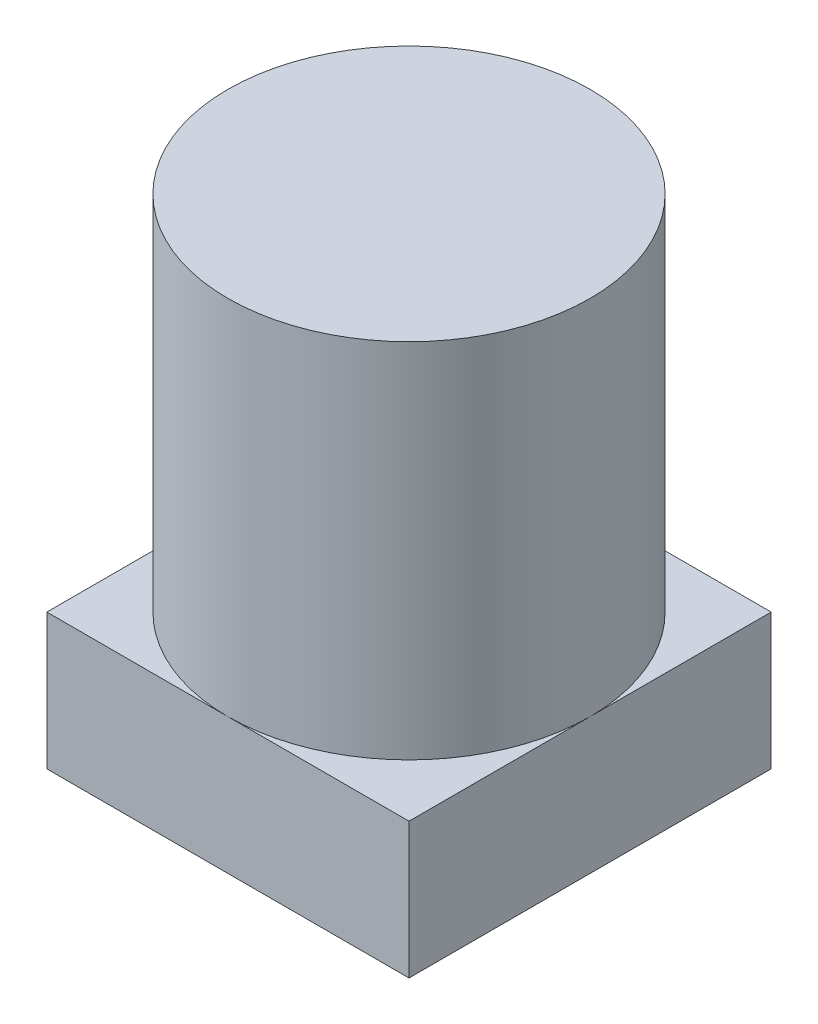
from build123d import *

# Parameters (mm, degrees)
SKETCH1_W           = 8
SKETCH1_H           = 8
BOSS_EXTRUDE1_DEPTH = 3
SKETCH2_R           = 4
BOSS_EXTRUDE2_DEPTH = 8


with BuildPart() as part:
    # Sketch1 → Boss-Extrude1 (new body)
    with BuildSketch(Plane(origin=(0, 0, 0), x_dir=(1, 0, 0), z_dir=(0, 1, 0))):
        with Locations((1.309734513, -1.469026549)):
            Rectangle(SKETCH1_W, SKETCH1_H)
    extrude(amount=BOSS_EXTRUDE1_DEPTH)

    # Sketch2 → Boss-Extrude2 (add)
    with BuildSketch(Plane(origin=(0, 3, 0), x_dir=(1, 0, 0), z_dir=(0, 1, 0))):
        with Locations(Location((1.309734513, -1.469026549, 0), (0, 0, 270))):  # turned: the seam where the file's is
            Circle(SKETCH2_R)
    extrude(amount=BOSS_EXTRUDE2_DEPTH)


solid = part.part
